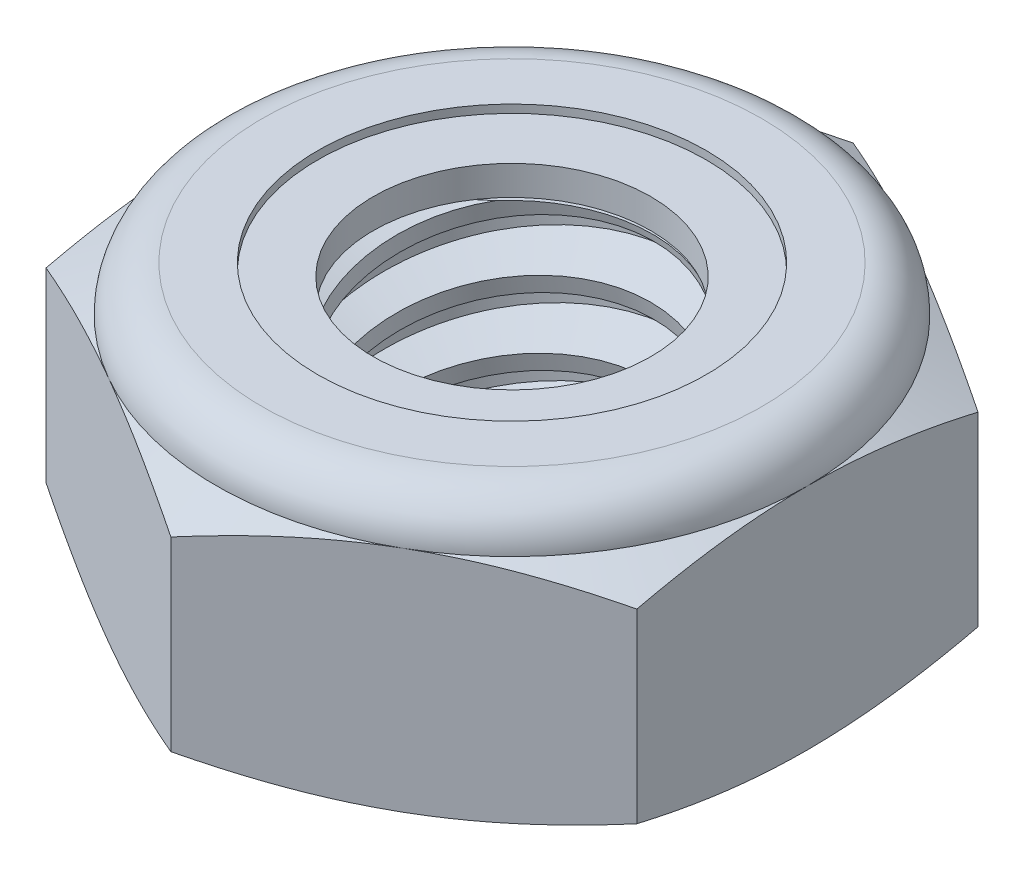
from build123d import *

# Parameters (mm, degrees)
EXTRUDE1_DEPTH       = 5.159375
SKETCH2_W            = 3.175
SKETCH2_H            = 5.159375
LPATTERN1_COUNT      = 4
LPATTERN1_PITCH      = 1.27
LPATTERN1_COUNT_DIR2 = 2
LPATTERN1_PITCH_DIR2 = 1.27


with BuildPart() as part:
    # Sketch1 → Extrude1 (new body)
    with BuildSketch(Plane(origin=(0, 0, 0), x_dir=(1, 0, 0), z_dir=(0, 1, 0))):
        Polygon((0, 6.415804866), (-5.55625, 3.207902433), (-5.55625, -3.207902433), (0, -6.415804866), (5.55625, -3.207902433), (5.55625, 3.207902433), align=None)
    extrude(amount=EXTRUDE1_DEPTH)

    # Sketch4 → Cut-Revolve2 (revolve, cut)
    with BuildSketch(Plane(origin=(0, 0, 0), x_dir=(0, 0, -1), z_dir=(1, 0, 0))):
        Polygon((0, 5.159375), (3.175, 5.159375), (2.609908356, 4.895868439), (2.609908356, 0.263506561), (3.175, 0), (0, 0), align=None)
    revolve(axis=Axis((0, 5.159375, 0), (0, 1, 0)), mode=Mode.SUBTRACT)


with BuildPart() as body_2:
    # Sketch2 → Revolve1 (revolve)
    with BuildSketch(Plane(origin=(0, 0, 0), x_dir=(0, 0, -1), z_dir=(1, 0, 0))):
        with Locations((1.5875, 2.5796875)):
            Rectangle(SKETCH2_W, SKETCH2_H)
    revolve(axis=Axis((0, -3.175, 0), (0, 1, 0)))

    # Sketch3 → Cut-Revolve1 (revolve, cut)
    with BuildSketch(Plane(origin=(0, 0, 0), x_dir=(0, 0, -1), z_dir=(1, 0, 0))):
        Polygon((3.206133436, 5.003707818), (3.424067492, 3.914037542), (2.672175229, 4.168393763), (2.609908356, 4.479728128), align=None)
    cut_revolve1 = revolve(axis=Axis((0, 5.159375, 0.272704483), (0, -0.9805806756909201, -0.19611613513818454)), mode=Mode.SUBTRACT)

    # LPattern1: Cut-Revolve1 4 × 2
    with Locations(*[Vector(0, -1, 0) * (i * LPATTERN1_PITCH) + Vector(0, 1, 0) * (j * LPATTERN1_PITCH_DIR2) for i in range(LPATTERN1_COUNT) for j in range(LPATTERN1_COUNT_DIR2) if (i, j) != (0, 0)]):
        add(cut_revolve1, mode=Mode.SUBTRACT)


with BuildPart() as part_1:
    add(part.part)

    # Combine1: cut body 2
    add(body_2.part, mode=Mode.SUBTRACT)

    # Sketch5 → Cut-Revolve3 (revolve, cut)
    with BuildSketch(Plane(origin=(0, 0, 0), x_dir=(0, 0, -1), z_dir=(1, 0, 0))):
        with BuildLine():
            Line((0, 0), (5.55625, 0))
            Line((5.55625, 0), (6.415804866, 0.400817017))
            Line((6.415804866, 0.400817017), (6.415804866, 3.89866215))
            Line((6.415804866, 3.89866215), (5.55625, 4.299479167))
            ThreePointArc((5.55625, 4.299479167), (5.304392342, 4.907517342), (4.696354167, 5.159375))
            Line((4.696354167, 5.159375), (4.696354167, 6.429375))
            Line((4.696354167, 6.429375), (7.685804866, 6.429375))
            Line((7.685804866, 6.429375), (7.685804866, -1.27))
            Line((7.685804866, -1.27), (0, -1.27))
            Line((0, -1.27), (0, 0))
        make_face()
    revolve(axis=Axis((0, 0, 0), (0, 1, 0)), mode=Mode.SUBTRACT)

    # Sketch6 → Cut-Revolve4 (revolve, cut)
    with BuildSketch(Plane(origin=(0, 0, 0), x_dir=(0, 0, -1), z_dir=(1, 0, 0))):
        with BuildLine():
            Line((0, 4.299479167), (5.40385, 4.299479167))
            ThreePointArc((5.40385, 4.299479167), (5.196629268, 4.799754268), (4.696354167, 5.006975))
            Line((4.696354167, 5.006975), (3.653131261, 5.006975))
            Line((3.653131261, 5.006975), (3.653131261, 6.429375))
            Line((3.653131261, 6.429375), (0, 6.429375))
            Line((0, 6.429375), (0, 4.299479167))
        make_face()
    revolve(axis=Axis((0, 6.429375, 0), (0, 1, 0)), mode=Mode.SUBTRACT)


with BuildPart() as body_2_2:
    # Sketch7 → Revolve2 (revolve)
    with BuildSketch(Plane(origin=(0, 0, 0), x_dir=(0, 0, -1), z_dir=(1, 0, 0))):
        with BuildLine():
            Line((2.609908356, 4.375679167), (5.3230343, 4.375679167))
            ThreePointArc((5.3230343, 4.375679167), (5.114940888, 4.772046184), (4.696354167, 4.930775))
            Line((4.696354167, 4.930775), (2.609908356, 4.930775))
            Line((2.609908356, 4.930775), (2.609908356, 4.375679167))
        make_face()
    revolve(axis=Axis((0, 4.375679167, 0), (0, 1, 0)))


solid = Compound([part_1.part, body_2_2.part])
